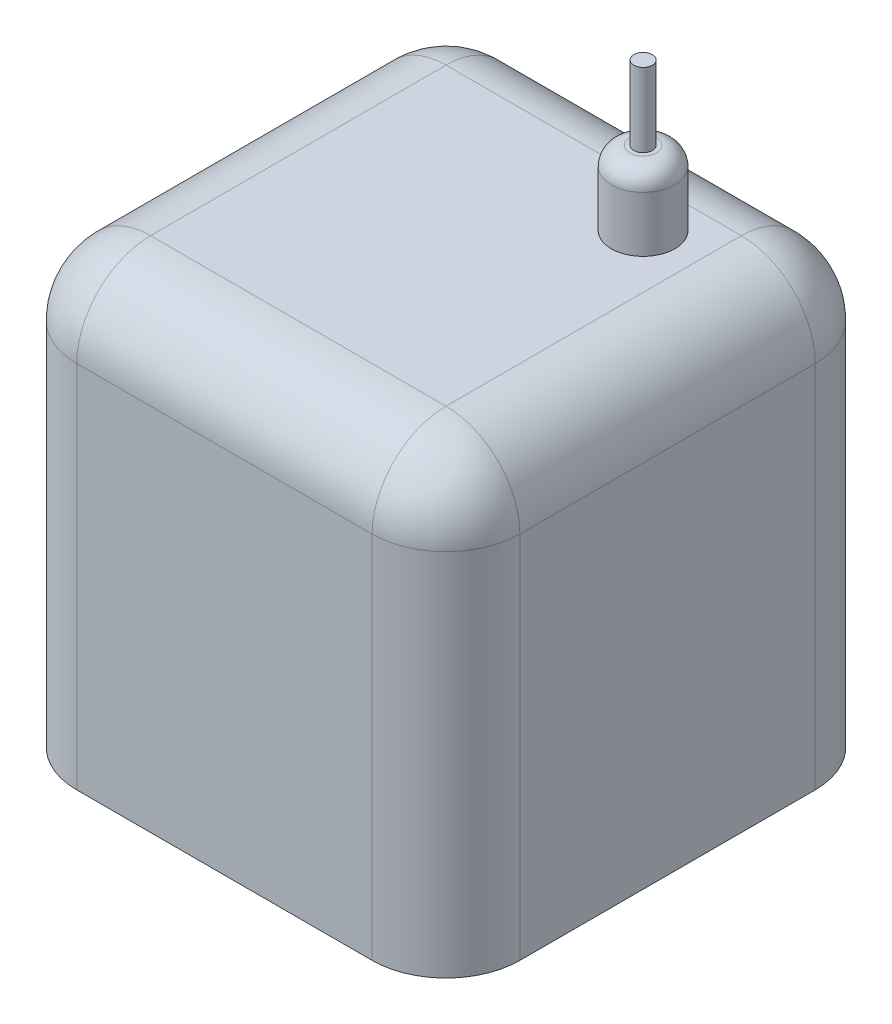
from build123d import *

# Parameters (mm, degrees)
SKETCH1_W           = 120
SKETCH1_H           = 120
BOSS_EXTRUDE1_DEPTH = 120
FILLET1_R           = 20
SKETCH4_R           = 8.6064573
BOSS_EXTRUDE4_DEPTH = 20
SKETCH5_R           = 2.5
BOSS_EXTRUDE5_DEPTH = 20
FILLET2_R           = 5


with BuildPart() as part:
    # Sketch1 → Boss-Extrude1 (new body)
    with BuildSketch(Plane(origin=(0, 0, 0), x_dir=(1, 0, 0), z_dir=(0, 1, 0))):
        with Locations((54, -46.284032095)):
            Rectangle(SKETCH1_W, SKETCH1_H)
    extrude(amount=BOSS_EXTRUDE1_DEPTH)

    # Fillet1
    fillet1_edges = [part.edges().sort_by_distance(p)[0] for p in [
        (-6, 120, 46.284032095),
        (54, 120, 106.284032095),
        (114, 120, 46.284032095),
        (54, 120, -13.715967905),
        (114, 60, 106.284032095),
        (-6, 60, 106.284032095),
        (-6, 60, -13.715967905),
        (114, 60, -13.715967905),
    ]]
    fillet(fillet1_edges, radius=FILLET1_R)

    # Sketch4 → Boss-Extrude4 (add)
    with BuildSketch(Plane(origin=(0, 120, 0), x_dir=(1, 0, 0), z_dir=(0, 1, 0))):
        with Locations((79.473330559, -18.374712085)):
            Circle(SKETCH4_R)
    extrude(amount=BOSS_EXTRUDE4_DEPTH)

    # Sketch5 → Boss-Extrude5 (add)
    with BuildSketch(Plane(origin=(0, 140, 0), x_dir=(1, 0, 0), z_dir=(0, 1, 0))):
        with Locations((79.473330559, -18.374712085)):
            Circle(SKETCH5_R)
    extrude(amount=BOSS_EXTRUDE5_DEPTH)

    # Fillet2
    fillet2_edges = [part.edges().sort_by_distance(p)[0] for p in [
        (70.866873258, 140, 18.374712085),
    ]]
    fillet(fillet2_edges, radius=FILLET2_R)


solid = part.part
